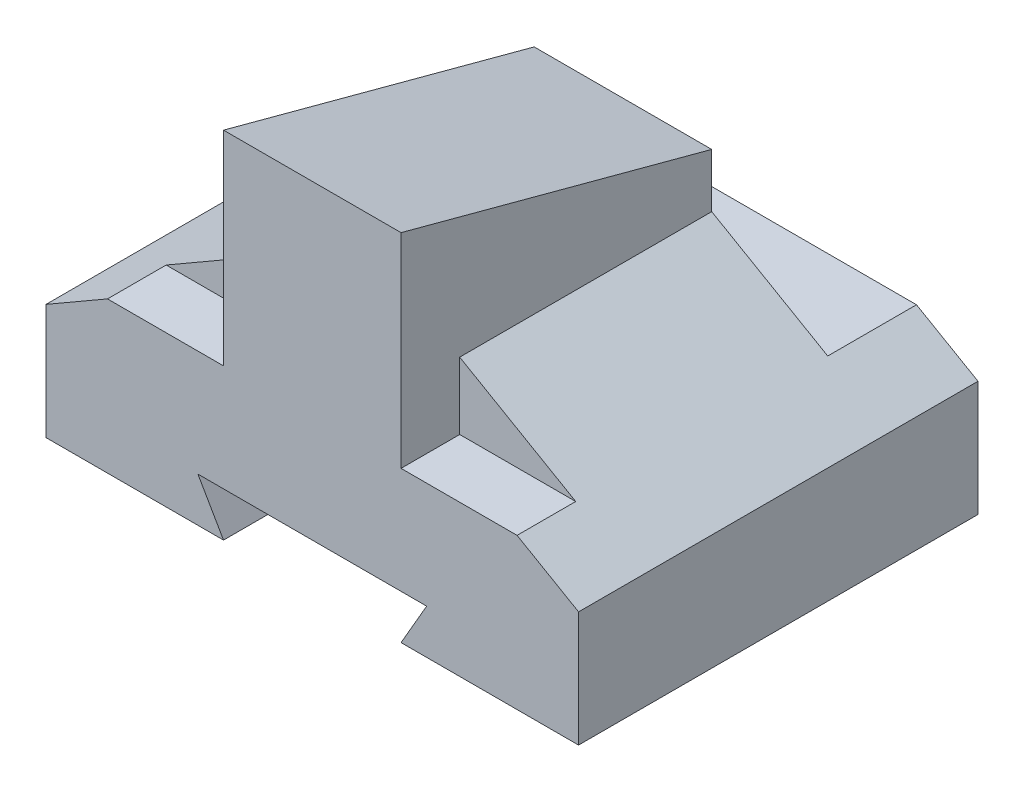
from build123d import *

# Parameters (mm, degrees)
SKETCH2_W           = 60
SKETCH2_H           = 45
BOSS_EXTRUDE1_DEPTH = 13
BOSS_EXTRUDE2_DEPTH = 45
SKETCH11_W          = 60
SKETCH11_H          = 10
SKETCH11_H_2        = 6.608108108
CUT_EXTRUDE2_DEPTH  = 21
BOSS_EXTRUDE3_REACH = 42
SKETCH12_W          = 20
SKETCH12_H          = 35
DRAFT1_ANGLE        = -15
CUT_EXTRUDE3_DEPTH  = 46


with BuildPart() as part:
    # Sketch2 → Boss-Extrude1 (new body)
    with BuildSketch(Plane(origin=(0, 0, 0), x_dir=(1, 0, 0), z_dir=(0, 1, 0))):
        Rectangle(SKETCH2_W, SKETCH2_H)
    extrude(amount=BOSS_EXTRUDE1_DEPTH)

    # Sketch3 → Boss-Extrude2 (add)
    with BuildSketch(Plane.XY.offset(22.5)):
        Polygon((0, 30.320508076), (30, 13), (-30, 13), align=None)
    extrude(amount=-BOSS_EXTRUDE2_DEPTH)

    # Sketch11 → Cut-Extrude2 (cut)
    with BuildSketch(Plane(origin=(0, 38, 0), x_dir=(-1, 0, 0), z_dir=(0, -1, 0))):
        with Locations((0, 17.5)):
            Rectangle(SKETCH11_W, SKETCH11_H)
        with Locations((0, -19.195945946)):
            Rectangle(SKETCH11_W, SKETCH11_H_2)
    extrude(amount=CUT_EXTRUDE2_DEPTH, mode=Mode.SUBTRACT)

    # Sketch12 → Boss-Extrude3 (add, up to next)
    with BuildSketch(Plane(origin=(0, 40, 0), x_dir=(-1, 0, 0), z_dir=(0, -1, 0)), mode=Mode.PRIVATE) as boss_extrude3_sk1:
        with Locations((0, -5)):
            Rectangle(SKETCH12_W, SKETCH12_H)
    boss_extrude3_tool1 = extrude(boss_extrude3_sk1.sketch, amount=BOSS_EXTRUDE3_REACH, mode=Mode.PRIVATE) - part.part
    add(boss_extrude3_tool1.solids().sort_by_distance((0, 40, 5))[0])

    # Draft1
    draft1_faces = [part.faces().sort_by_distance(p)[0] for p in [
        (0, 40, 5),
    ]]
    draft(draft1_faces, Plane(origin=(30, 13, 22.5), x_dir=(1, 0, 0), z_dir=(0, 0, 1)), DRAFT1_ANGLE)

    # Sketch16 → Cut-Extrude3 (cut, through all)
    with BuildSketch(Plane(origin=(0, 0, -22.5), x_dir=(-1, 0, 0), z_dir=(0, 0, -1))):
        Polygon((-12.886751346, 5), (-10, 0), (10, 0), (12.886751346, 5), align=None)
    extrude(amount=-CUT_EXTRUDE3_DEPTH, mode=Mode.SUBTRACT)


solid = part.part
